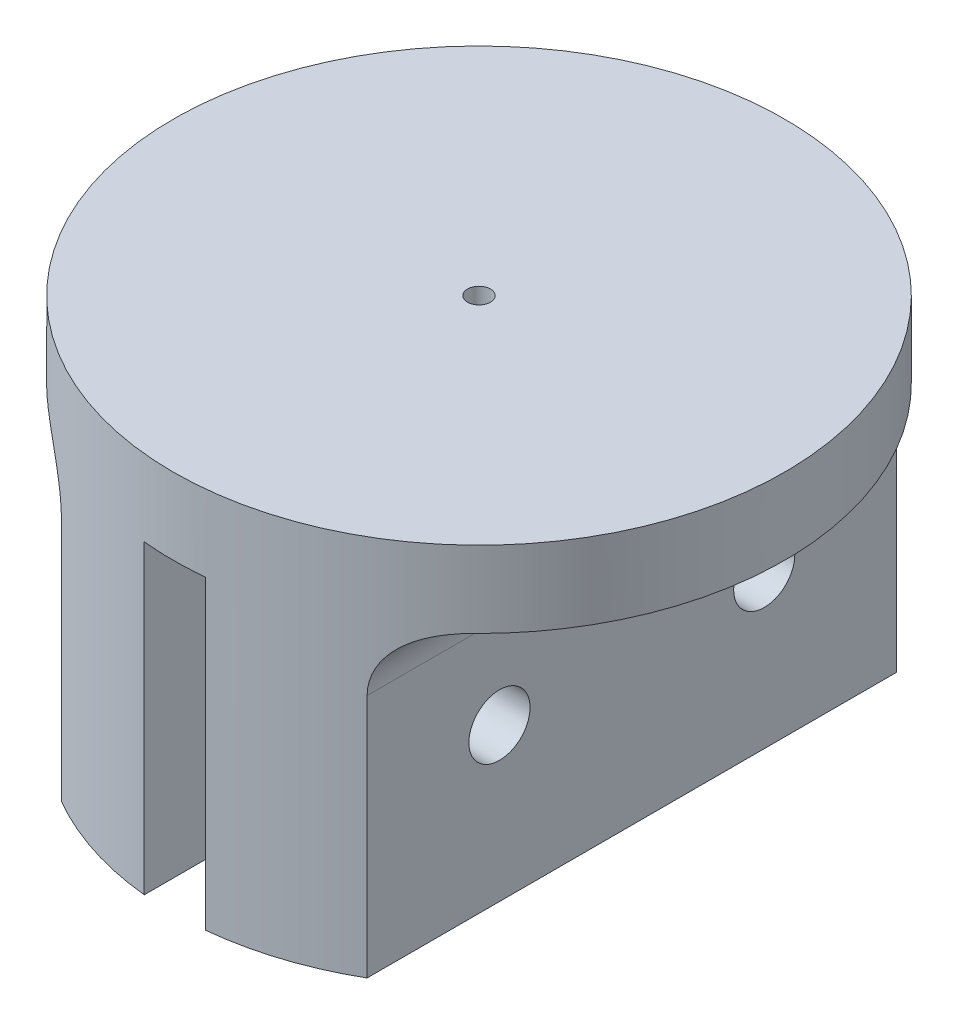
from build123d import *

# Parameters (mm, degrees)
ESBO_O1_R                  = 20
ESBO_O1_R_2                = 0.75
RESSALTO_EXTRUS_O1_DEPTH   = 25
ESBO_O2_W                  = 4
ESBO_O2_H                  = 42.07133093
ESBO_O2_W_2                = 15.138637908
ESBO_O2_H_2                = 40
ESBO_O2_W_3                = 12.263470243
CORTE_EXTRUS_O1_DEPTH      = 20
ESBO_O3_R                  = 2
CORTE_EXTRUS_O2_DEPTH      = 20
CORTE_EXTRUS_O2_DEPTH_BACK = 20
FILETE1_R                  = 4


with BuildPart() as part:
    # Esboço1 → Ressalto-extrusão1 (new body)
    with BuildSketch(Plane(origin=(0, 0, 0), x_dir=(1, 0, 0), z_dir=(0, 1, 0))):
        Circle(ESBO_O1_R)
        Circle(ESBO_O1_R_2, mode=Mode.SUBTRACT)
    extrude(amount=RESSALTO_EXTRUS_O1_DEPTH)

    # Esboço2 → Corte-extrusão1 (cut)
    with BuildSketch(Plane(origin=(0, 0, 0), x_dir=(1, 0, 0), z_dir=(0, 1, 0))):
        with Locations((0, -0.26404601)):
            Rectangle(ESBO_O2_W, ESBO_O2_H)
        with Locations((-17.569318954, 0)):
            Rectangle(ESBO_O2_W_2, ESBO_O2_H_2)
        with Locations((16.131735122, -0.26404601)):
            Rectangle(ESBO_O2_W_3, ESBO_O2_H)
    extrude(amount=CORTE_EXTRUS_O1_DEPTH, mode=Mode.SUBTRACT)

    # Esboço3 → Corte-extrusão2 (cut, two sides)
    with BuildSketch(Plane(origin=(0, 0, 0), x_dir=(0, 0, -1), z_dir=(1, 0, 0))) as corte_extrus_o2_sk:
        with Locations((-8.660254038, 10)):
            Circle(ESBO_O3_R)
        with Locations((8.660254038, 10)):
            Circle(ESBO_O3_R)
    extrude(amount=CORTE_EXTRUS_O2_DEPTH, mode=Mode.SUBTRACT)
    extrude(corte_extrus_o2_sk.sketch, amount=-CORTE_EXTRUS_O2_DEPTH_BACK, mode=Mode.SUBTRACT)

    # Filete1
    filete1_edges = [part.edges().sort_by_distance(p)[0] for p in [
        (-10, 20, 0),
        (10, 20, 0),
    ]]
    fillet(filete1_edges, radius=FILETE1_R)


solid = part.part
